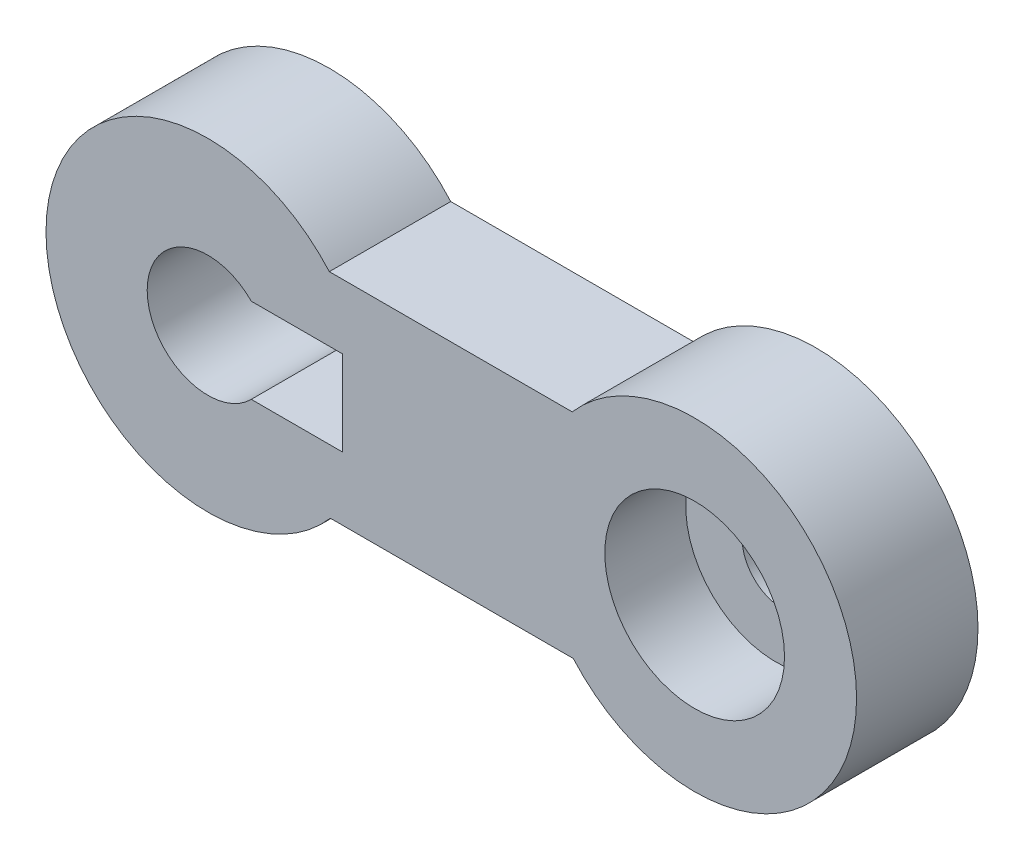
from build123d import *

# Parameters (mm, degrees)
BOSS_EXTRUDE3_DEPTH = 15
SKETCH5_R           = 11.1
CUT_EXTRUDE2_DEPTH  = 10
SKETCH8_R           = 5
CUT_EXTRUDE5_DEPTH  = 10
SKETCH10_R          = 7.5
SKETCH10_W          = 12
SKETCH10_H          = 10.5
CUT_EXTRUDE6_DEPTH  = 16


with BuildPart() as part:
    # Sketch4 → Boss-Extrude3 (new body)
    with BuildSketch(Plane.XY):
        with BuildLine():
            Line((-31.83399024, -2.564162853), (-1.83399024, -2.564162853))
            ThreePointArc((-1.83399024, -2.564162853), (33.162534063, 10.767212745), (-1.964197709, 23.75162662))
            Line((-1.964197709, 23.75162662), (-31.964197709, 23.75162662))
            ThreePointArc((-31.964197709, 23.75162662), (-66.960722012, 10.420251021), (-31.83399024, -2.564162853))
        make_face()
    extrude(amount=BOSS_EXTRUDE3_DEPTH)

    # Sketch5 → Cut-Extrude2 (cut)
    with BuildSketch(Plane.XY.offset(15)):
        with Locations((13.162778875, 10.66825628)):
            Circle(SKETCH5_R)
    extrude(amount=-CUT_EXTRUDE2_DEPTH, mode=Mode.SUBTRACT)

    # Sketch8 → Cut-Extrude5 (cut)
    with BuildSketch(Plane.XY.offset(5)):
        with Locations((14.03064546, 10.66825628)):
            Circle(SKETCH8_R)
    extrude(amount=-CUT_EXTRUDE5_DEPTH, mode=Mode.SUBTRACT)

    # Sketch10 → Cut-Extrude6 (cut, through all)
    with BuildSketch(Plane(origin=(0, 0, 0), x_dir=(-1, 0, 0), z_dir=(0, 0, -1))):
        with Locations((46.960966823, 10.519207486)):
            Circle(SKETCH10_R)
        with Locations((36.330902029, 10.519207486)):
            Rectangle(SKETCH10_W, SKETCH10_H)
    extrude(amount=-CUT_EXTRUDE6_DEPTH, mode=Mode.SUBTRACT)


solid = part.part
